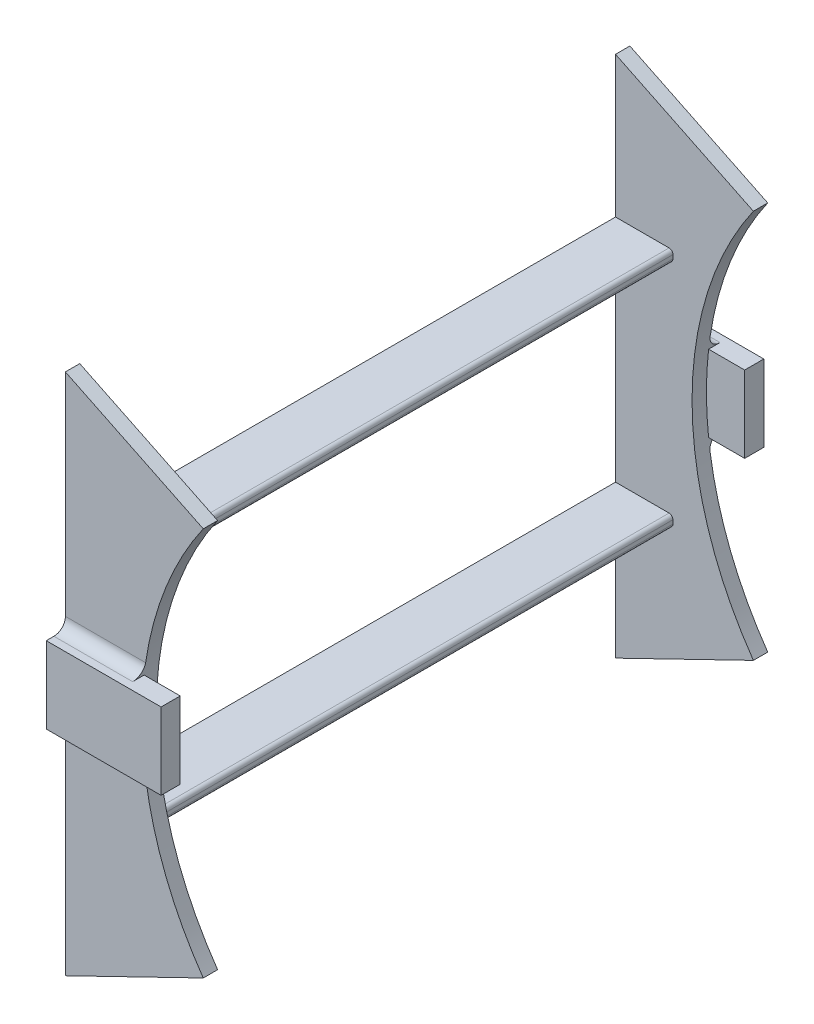
from build123d import *

# Parameters (mm, degrees)
BOSS_EXTRUDE1_DEPTH = 1.875
BOSS_EXTRUDE3_DEPTH = 140
BOSS_EXTRUDE4_DEPTH = 5
FILLET4_R           = 3


with BuildPart() as part:
    # Sketch1 → Boss-Extrude1 (new body, symmetric)
    with BuildSketch(Plane.XY):
        with BuildLine():
            Line((-72.585877034, -50.825178267), (-108.610994186, -68.325178267))
            Line((-108.610994186, -68.325178267), (-108.610994186, 68.325178267))
            Line((-108.610994186, 68.325178267), (-72.585877034, 50.825178267))
            ThreePointArc((-72.585877034, 50.825178267), (-88.610994186, 0), (-72.585877034, -50.825178267))
        make_face()
    boss_extrude1 = extrude(amount=BOSS_EXTRUDE1_DEPTH, both=True)

    # Sketch3 → Boss-Extrude3 (add)
    with BuildSketch(Plane.XY.offset(1.875)):
        with BuildLine():
            Line((-108.610994186, -28.5), (-108.610994186, -31.5))
            Line((-108.610994186, -31.5), (-94.610994186, -31.5))
            ThreePointArc((-94.610994186, -31.5), (-93.903887405, -31.207106781), (-93.610994186, -30.5))
            Line((-93.610994186, -30.5), (-93.610994186, -29.5))
            ThreePointArc((-93.610994186, -29.5), (-93.903887405, -28.792893219), (-94.610994186, -28.5))
            Line((-94.610994186, -28.5), (-108.610994186, -28.5))
        make_face()
    boss_extrude3 = extrude(amount=BOSS_EXTRUDE3_DEPTH)

    # Mirror2: Boss-Extrude3 across plane
    add(boss_extrude3.mirror(Plane.ZX))

    # Mirror7: Boss-Extrude1 across plane
    add(boss_extrude1.mirror(Plane.XY.offset(71.875)))

    # Sketch4 → Boss-Extrude4 (add)
    with BuildSketch(Plane(origin=(0, 0, -1.875), x_dir=(-1, 0, 0), z_dir=(0, 0, -1))):
        Polygon((108.610994186, 0), (108.610994186, 10), (78.610994186, 10), (78.610994186, -10), (108.610994186, -10), align=None)
    boss_extrude4 = extrude(amount=BOSS_EXTRUDE4_DEPTH)

    # Mirror10: Boss-Extrude4 across plane
    add(boss_extrude4.mirror(Plane.XY.offset(71.875)))

    # Fillet4
    fillet4_edges = [part.edges().sort_by_distance(p)[0] for p in [
        (-98.327958095, -10, -1.875),
        (-98.327958095, 10, -1.875),
        (-98.327958095, -10, 145.625),
        (-98.327958095, 10, 145.625),
    ]]
    fillet(fillet4_edges, radius=FILLET4_R)


solid = part.part
